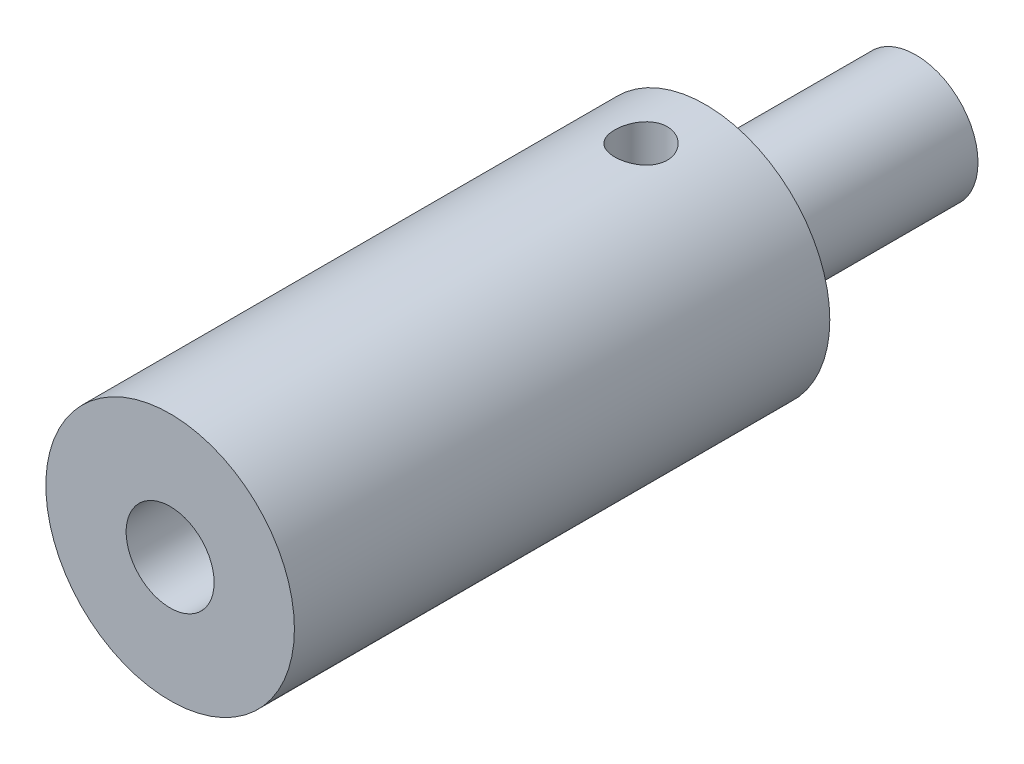
from build123d import *

# Parameters (mm, degrees)
CROQUIS1_R                 = 13
CROQUIS1_R_2               = 4.6
SALIENTE_EXTRUIR1_DEPTH    = 40
SALIENTE_EXTRUIR2_START    = -16
CROQUIS1_2_R               = 13
SALIENTE_EXTRUIR2_DEPTH    = 16
CROQUIS2_R                 = 6.5
SALIENTE_EXTRUIR3_DEPTH    = 22
REDONDEO1_R                = 0.5
REDONDEO2_R                = 0.5
CORTAR_EXTRUIR1_DEPTH      = 45.022721406
CORTAR_EXTRUIR1_DEPTH_BACK = 45.022721406
CROQUIS3_R                 = 2.75


with BuildPart() as part:
    # Croquis1 → Saliente-Extruir1 (new body)
    with BuildSketch(Plane.XY):
        Circle(CROQUIS1_R)
        Circle(CROQUIS1_R_2, mode=Mode.SUBTRACT)
    extrude(amount=SALIENTE_EXTRUIR1_DEPTH)

    # Croquis1_2 → Saliente-Extruir2 (add)
    with BuildSketch(Plane.XY.offset(SALIENTE_EXTRUIR2_START)):
        Circle(CROQUIS1_2_R)
    extrude(amount=SALIENTE_EXTRUIR2_DEPTH)

    # Croquis2 → Saliente-Extruir3 (add)
    with BuildSketch(Plane(origin=(0, 0, -16), x_dir=(-1, 0, 0), z_dir=(0, 0, -1))):
        Circle(CROQUIS2_R)
    extrude(amount=SALIENTE_EXTRUIR3_DEPTH)

    # Redondeo1
    redondeo1_edges = [part.edges().sort_by_distance(p)[0] for p in [
        (6.5, 0, -16),
    ]]
    fillet(redondeo1_edges, radius=REDONDEO1_R)

    # Redondeo2
    redondeo2_edges = [part.edges().sort_by_distance(p)[0] for p in [
        (-4.6, 0, 0),
    ]]
    fillet(redondeo2_edges, radius=REDONDEO2_R)

    # Croquis3 → Cortar-Extruir1 (cut, two sides: drawn at the far end of the back side and taken through both)
    with BuildSketch(Plane(origin=(0, 0, 0), x_dir=(1, 0, 0), z_dir=(0, 1, 0)).offset(-CORTAR_EXTRUIR1_DEPTH_BACK)):
        with Locations((0, 9.25)):
            Circle(CROQUIS3_R)
    extrude(amount=CORTAR_EXTRUIR1_DEPTH + CORTAR_EXTRUIR1_DEPTH_BACK, mode=Mode.SUBTRACT)


solid = part.part
